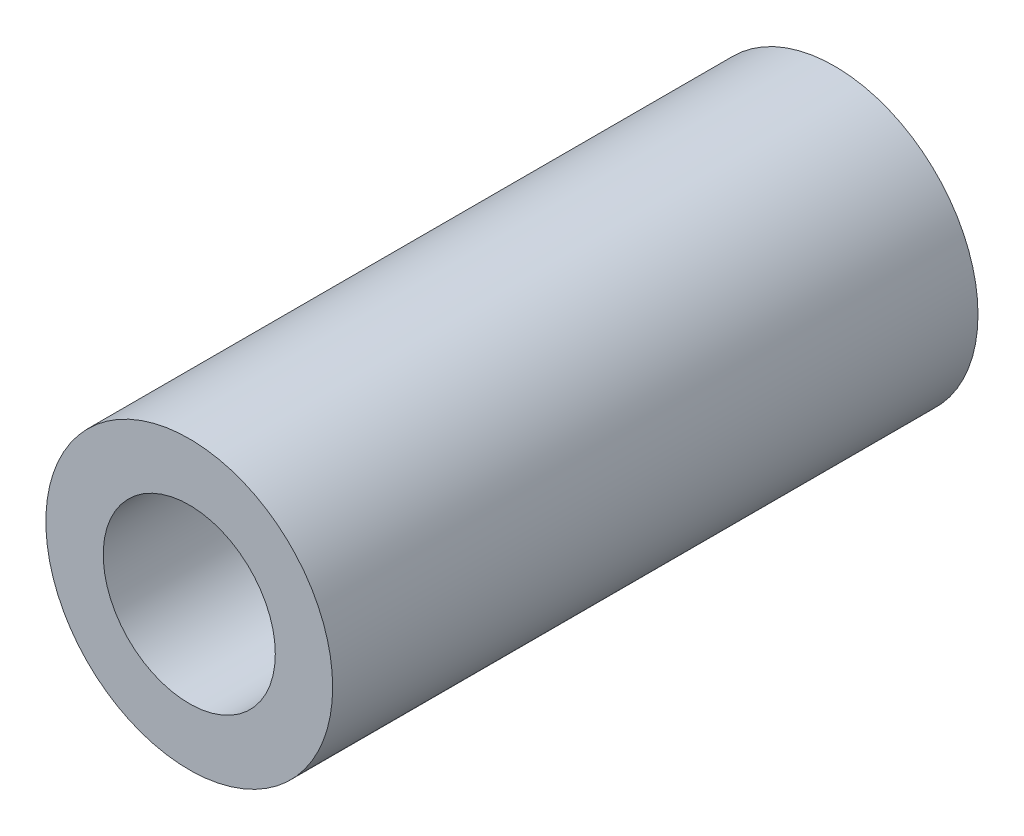
from build123d import *

# Parameters (mm, degrees)
SKETCH1_R           = 10
SKETCH1_R_2         = 6
BOSS_EXTRUDE1_DEPTH = 45


with BuildPart() as part:
    # Sketch1 → Boss-Extrude1 (new body)
    with BuildSketch(Plane.XY):
        Circle(SKETCH1_R)
        Circle(SKETCH1_R_2, mode=Mode.SUBTRACT)
    extrude(amount=BOSS_EXTRUDE1_DEPTH)


solid = part.part
